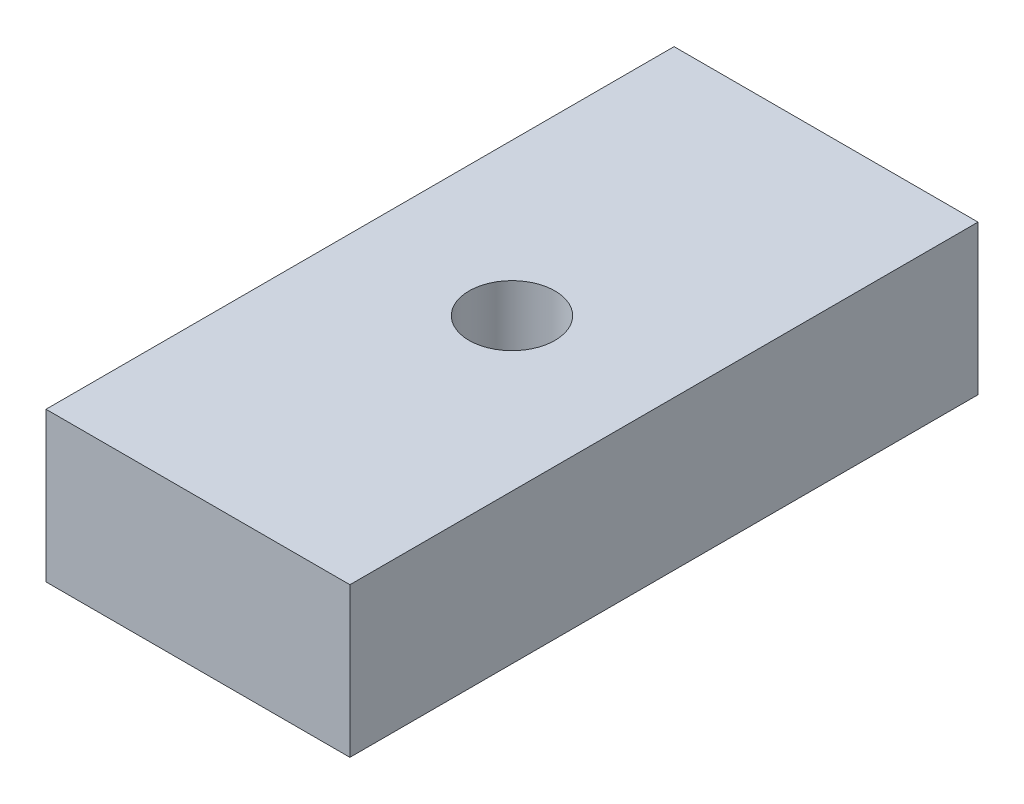
from build123d import *

# Parameters (mm, degrees)
SKETCH1_W             = 8.001
SKETCH1_H             = 16.5354
BOSS_EXTRUDE1_DEPTH   = 3.937
F_4_40_TAPPED_HOLE1_D = 2.2606


with BuildPart() as part:
    # Sketch1 → Boss-Extrude1 (new body)
    with BuildSketch(Plane(origin=(0, 0, 0), x_dir=(1, 0, 0), z_dir=(0, 1, 0))):
        Rectangle(SKETCH1_W, SKETCH1_H)
    extrude(amount=BOSS_EXTRUDE1_DEPTH)

    # 4-40 Tapped Hole1 (through all)
    with Locations(Plane(origin=(0, 3.937, 0), x_dir=(1, 0, 0), z_dir=(0, 1, 0))):
        with Locations((0, 0)):
            Hole(F_4_40_TAPPED_HOLE1_D / 2)


solid = part.part
